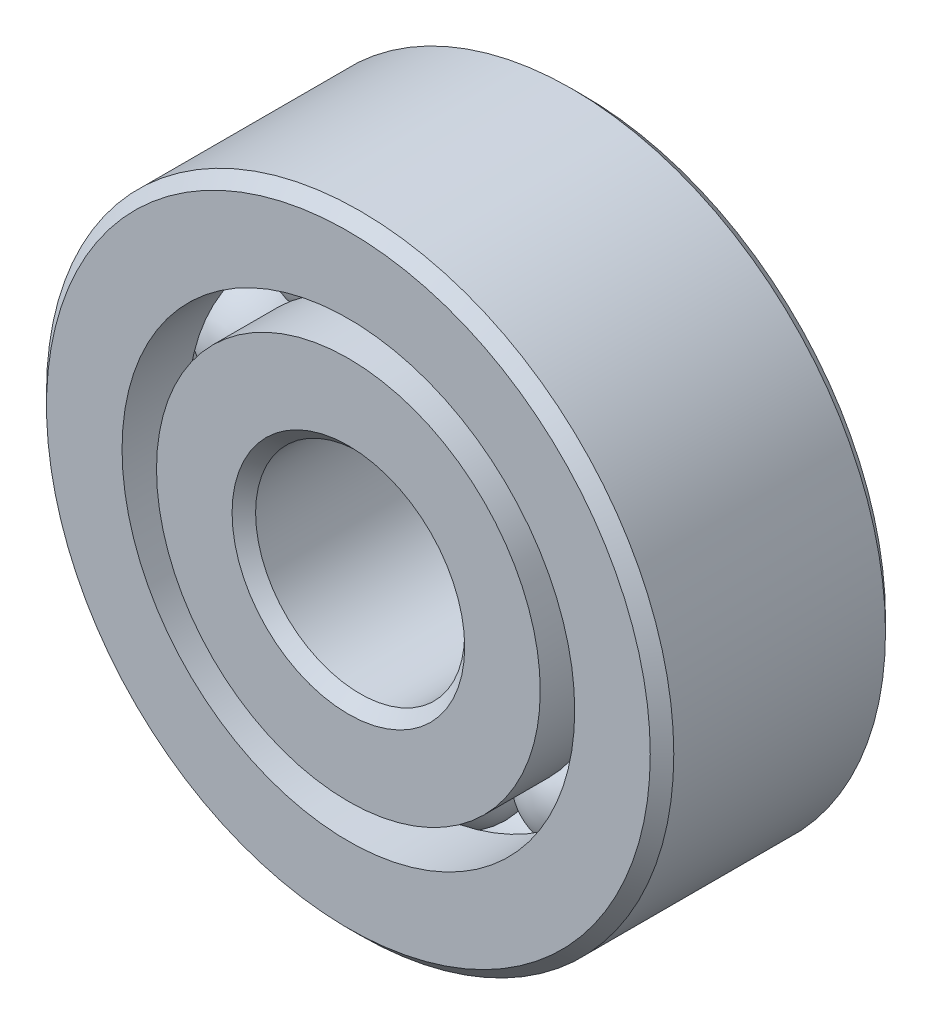
from build123d import *

# Parameters (mm, degrees)
CIRPATTERN1_COUNT = 10


with BuildPart() as part:
    # Sketch1 → Revolve1 (revolve)
    with BuildSketch(Plane(origin=(0, 0, 0), x_dir=(0, 0, -1), z_dir=(1, 0, 0))):
        with BuildLine():
            Line((3.2146875, 9.525), (-3.2146875, 9.525))
            Line((-3.2146875, 9.525), (-3.571875, 9.1678125))
            Line((-3.571875, 9.1678125), (-3.571875, 6.873351648))
            Line((-3.571875, 6.873351648), (-1.5875, 6.873351648))
            ThreePointArc((-1.5875, 6.873351648), (0, 8.021542162), (1.5875, 6.873351648))
            Line((1.5875, 6.873351648), (3.571875, 6.873351648))
            Line((3.571875, 6.873351648), (3.571875, 9.1678125))
            Line((3.571875, 9.1678125), (3.2146875, 9.525))
        make_face()
    revolve(axis=Axis((0, 0, 3.571875), (0, 0, -1)))


with BuildPart() as body_2:
    # Sketch3 → Revolve3 (revolve)
    with BuildSketch(Plane(origin=(0, 0, 0), x_dir=(0, 0, -1), z_dir=(1, 0, 0))):
        with BuildLine():
            Line((-3.571875, 5.826648352), (-1.5875, 5.826648352))
            ThreePointArc((-1.5875, 5.826648352), (0, 4.678457838), (1.5875, 5.826648352))
            Line((1.5875, 5.826648352), (3.571875, 5.826648352))
            Line((3.571875, 5.826648352), (3.571875, 3.5321875))
            Line((3.571875, 3.5321875), (3.2146875, 3.175))
            Line((3.2146875, 3.175), (-3.2146875, 3.175))
            Line((-3.2146875, 3.175), (-3.571875, 3.5321875))
            Line((-3.571875, 3.5321875), (-3.571875, 5.826648352))
        make_face()
    revolve(axis=Axis((0, 0, 3.571875), (0, 0, -1)))


with BuildPart() as body_3:
    # Sketch4 → Revolve4 (revolve)
    with BuildSketch(Plane(origin=(0, 0, 0), x_dir=(0, 0, -1), z_dir=(1, 0, 0))):
        with BuildLine():
            Line((-1.671542162, 6.35), (1.671542162, 6.35))
            ThreePointArc((1.671542162, 6.35), (0, 8.021542162), (-1.671542162, 6.35))
        make_face()
    revolve(axis=Axis((0, 6.35, 1.671542162), (0, 0, -1)))


with BuildPart() as cirpattern1_1:
    # CirPattern1: pattern copy
    add(body_3.part.rotate(Axis((0, 0, 0), (0, 0, 1)), 1 * 360 / CIRPATTERN1_COUNT))


with BuildPart() as cirpattern1_2:
    # CirPattern1: pattern copy
    add(body_3.part.rotate(Axis((0, 0, 0), (0, 0, 1)), 2 * 360 / CIRPATTERN1_COUNT))


with BuildPart() as cirpattern1_3:
    # CirPattern1: pattern copy
    add(body_3.part.rotate(Axis((0, 0, 0), (0, 0, 1)), 3 * 360 / CIRPATTERN1_COUNT))


with BuildPart() as cirpattern1_4:
    # CirPattern1: pattern copy
    add(body_3.part.rotate(Axis((0, 0, 0), (0, 0, 1)), 4 * 360 / CIRPATTERN1_COUNT))


with BuildPart() as cirpattern1_5:
    # CirPattern1: pattern copy
    add(body_3.part.rotate(Axis((0, 0, 0), (0, 0, 1)), 5 * 360 / CIRPATTERN1_COUNT))


with BuildPart() as cirpattern1_6:
    # CirPattern1: pattern copy
    add(body_3.part.rotate(Axis((0, 0, 0), (0, 0, 1)), 6 * 360 / CIRPATTERN1_COUNT))


with BuildPart() as cirpattern1_7:
    # CirPattern1: pattern copy
    add(body_3.part.rotate(Axis((0, 0, 0), (0, 0, 1)), 7 * 360 / CIRPATTERN1_COUNT))


with BuildPart() as cirpattern1_8:
    # CirPattern1: pattern copy
    add(body_3.part.rotate(Axis((0, 0, 0), (0, 0, 1)), 8 * 360 / CIRPATTERN1_COUNT))


with BuildPart() as cirpattern1_9:
    # CirPattern1: pattern copy
    add(body_3.part.rotate(Axis((0, 0, 0), (0, 0, 1)), 9 * 360 / CIRPATTERN1_COUNT))


solid = Compound([part.part, body_2.part, body_3.part, cirpattern1_1.part, cirpattern1_2.part, cirpattern1_3.part, cirpattern1_4.part, cirpattern1_5.part, cirpattern1_6.part, cirpattern1_7.part, cirpattern1_8.part, cirpattern1_9.part])
